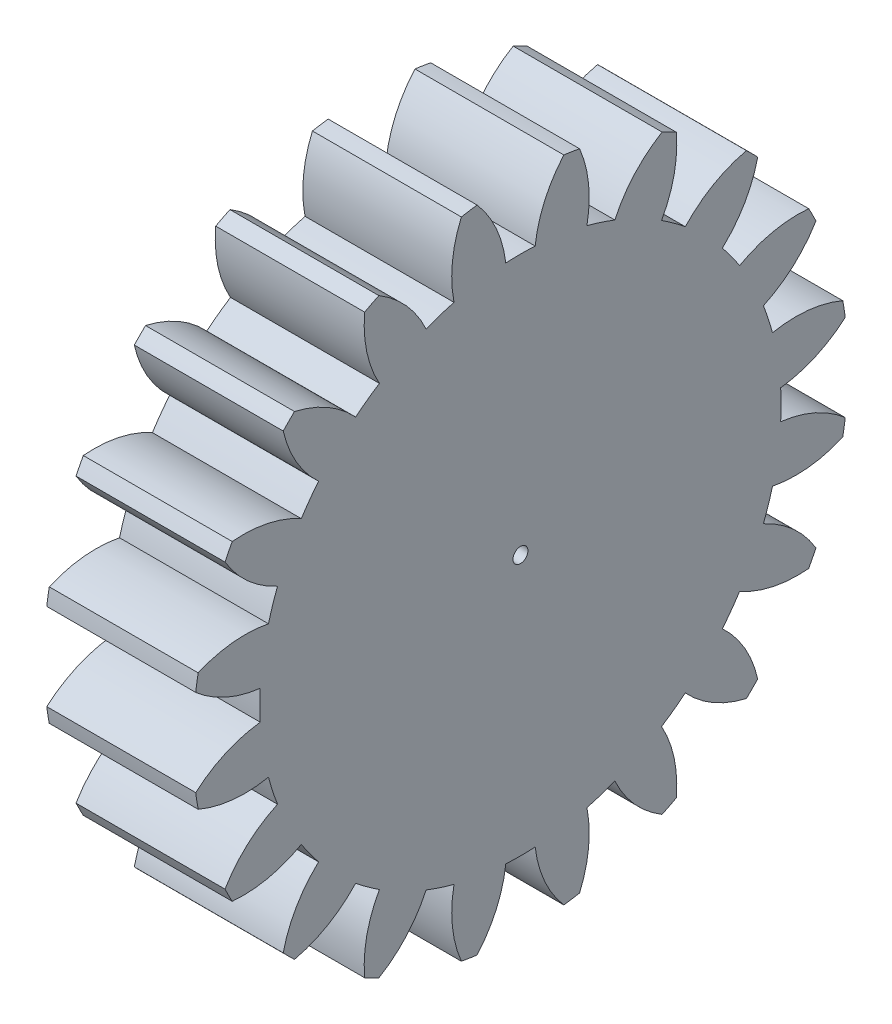
from build123d import *

# Parameters (mm, degrees)
BASPROSKE_W     = 10
BASPROSKE_H     = 22
TOOTHCUT_DEPTH  = 33.680269277
TEETHCUTS_COUNT = 20
TEETHCUTS_ANGLE = 342
BORSKE_R        = 0.5
BORE_DEPTH      = 50.0000508


with BuildPart() as part:
    # BasProSke → Base-Revolve (revolve)
    with BuildSketch(Plane(origin=(0, 0, 0), x_dir=(1, 0, 0), z_dir=(0, 1, 0)), mode=Mode.PRIVATE) as base_revolve_sk:
        with Locations((5, 11)):
            Rectangle(BASPROSKE_W, BASPROSKE_H)
    revolve(base_revolve_sk.sketch.rotate(Axis((-10, 0, 0), (1, 0, 0)), 180), axis=Axis((-10, 0, 0), (1, 0, 0)))

    # TooCutSke → ToothCut (cut, through all)
    with BuildSketch(Plane(origin=(0, 0, 0), x_dir=(0, 0, -1), z_dir=(1, 0, 0))):
        with BuildLine():
            ThreePointArc((0.986171591, 17.471189616), (0, 17.499), (-0.986171591, 17.471189616))
            ThreePointArc((-0.986171591, 17.471189616), (-1.626916196, 19.798789858), (-2.932850173, 21.829260982))
            ThreePointArc((-2.932850173, 21.829260982), (0, 22.0254), (2.932850173, 21.829260982))
            ThreePointArc((2.932850173, 21.829260982), (1.626916196, 19.798789858), (0.986171591, 17.471189616))
        make_face()
    toothcut = extrude(amount=TOOTHCUT_DEPTH, mode=Mode.SUBTRACT)

    # TeethCuts: ToothCut ×20 about axis
    teethcuts_axis = Axis((-10, 0, 0), (1, 0, 0))
    for i in range(1, TEETHCUTS_COUNT):
        add(toothcut.rotate(teethcuts_axis, i * TEETHCUTS_ANGLE / (TEETHCUTS_COUNT - 1)), mode=Mode.SUBTRACT)

    # BorSke → Bore (cut, symmetric)
    with BuildSketch(Plane(origin=(0, 0, 0), x_dir=(0, 0, -1), z_dir=(1, 0, 0))):
        with Locations(Location((0, 0, 0), (0, 0, 180))):
            Circle(BORSKE_R)
    extrude(amount=BORE_DEPTH, both=True, mode=Mode.SUBTRACT)


solid = part.part
